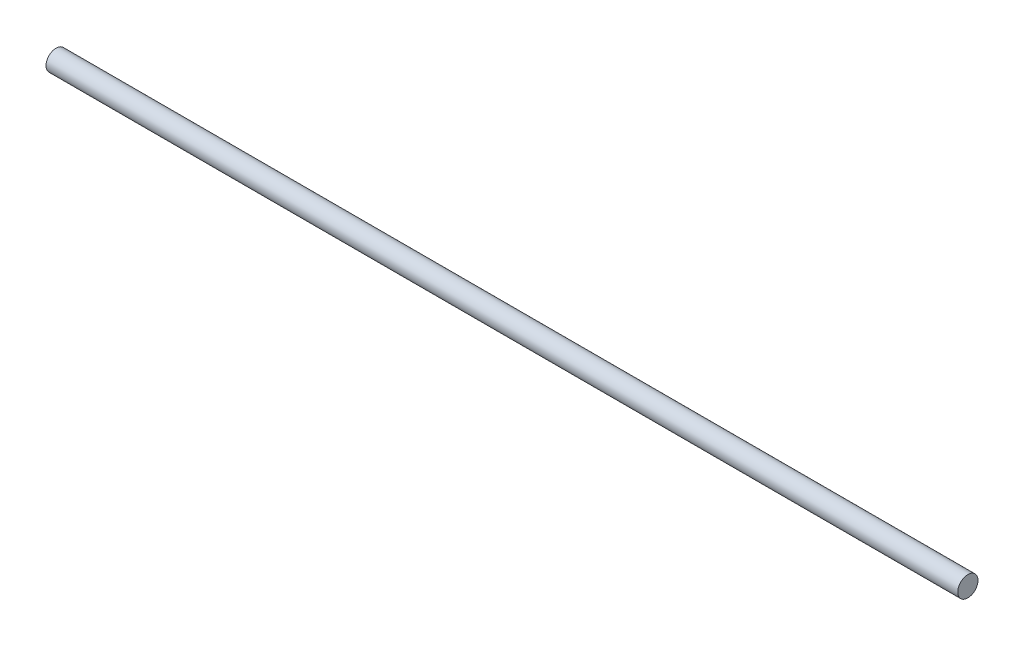
from build123d import *

# Parameters (mm, degrees)
SKETCH1_R           = 6.35
BOSS_EXTRUDE1_DEPTH = 571.5


with BuildPart() as part:
    # Sketch1 → Boss-Extrude1 (new body)
    with BuildSketch(Plane(origin=(0, 0, 0), x_dir=(0, 0, -1), z_dir=(1, 0, 0))):
        Circle(SKETCH1_R)
    extrude(amount=BOSS_EXTRUDE1_DEPTH)


solid = part.part
